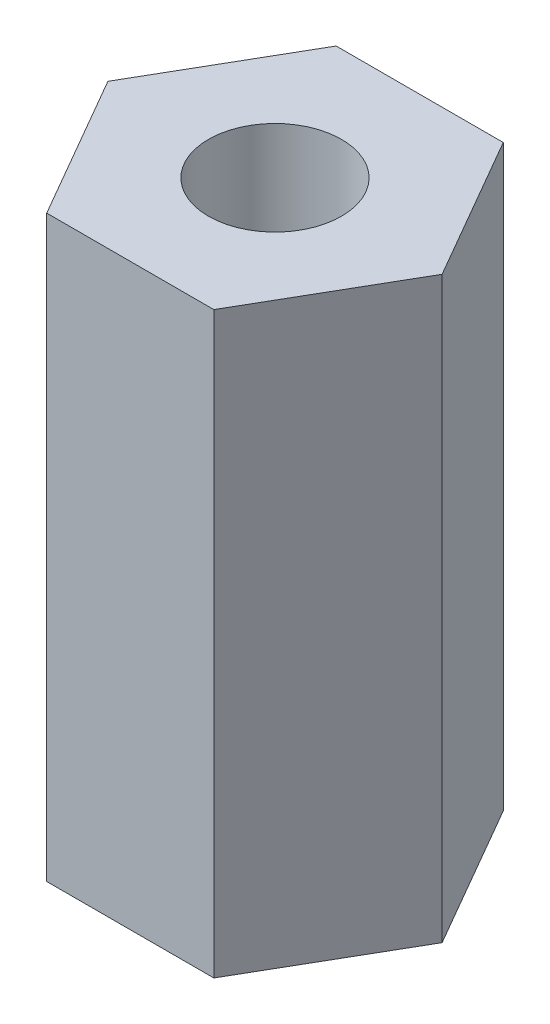
from build123d import *

# Parameters (mm, degrees)
SKETCH1_R           = 1.15
BOSS_EXTRUDE1_DEPTH = 10


with BuildPart() as part:
    # Sketch1 → Boss-Extrude1 (new body)
    with BuildSketch(Plane(origin=(0, 0, 0), x_dir=(1, 0, 0), z_dir=(0, 1, 0))):
        Polygon((2.886751346, 0), (1.443375673, 2.5), (-1.443375673, 2.5), (-2.886751346, 0), (-1.443375673, -2.5), (1.443375673, -2.5), align=None)
        Circle(SKETCH1_R, mode=Mode.SUBTRACT)
    extrude(amount=BOSS_EXTRUDE1_DEPTH)


solid = part.part
